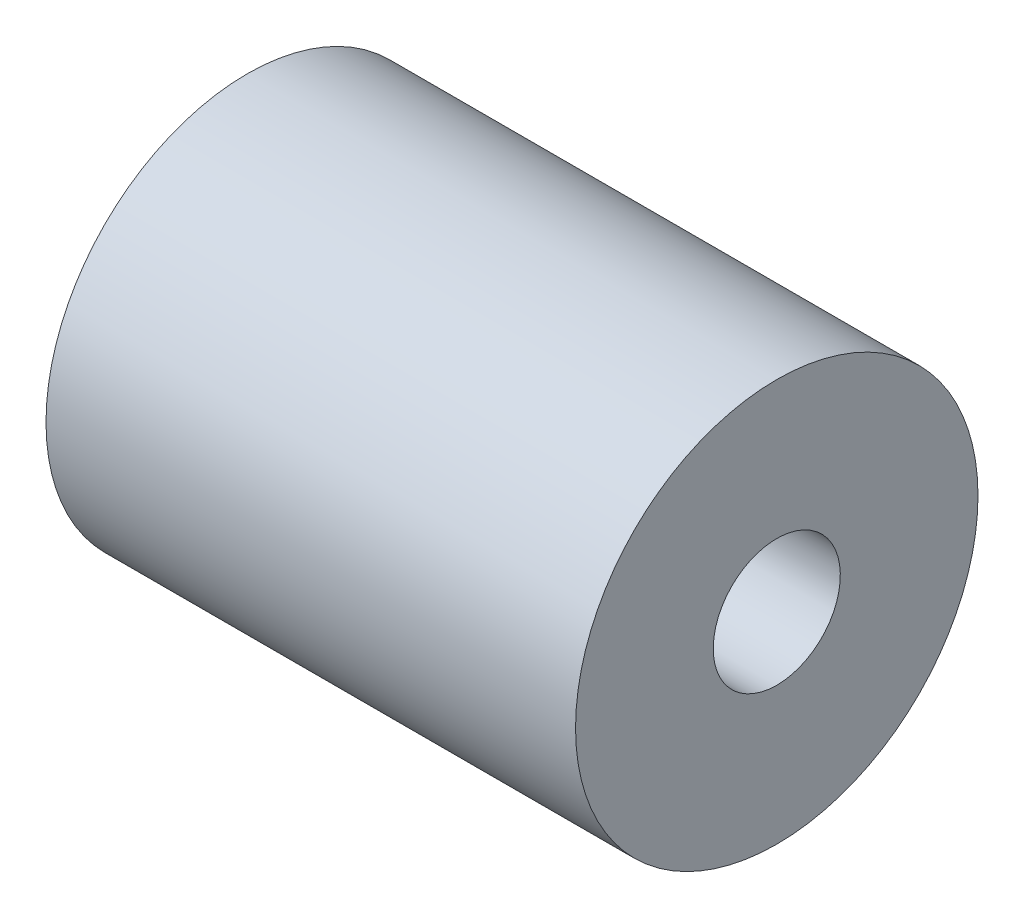
from build123d import *


with BuildPart() as part:
    # Sketch1 → Revolve1 (revolve)
    with BuildSketch(Plane.XY):
        Polygon((12.5, 3), (12.5, 9.5), (-12.5, 9.5), (-12.5, 4), (1.411382145, 4), (1.411382145, 3), align=None)
    revolve(axis=Axis((-12.5, 0, 0), (1, 0, 0)))


solid = part.part
